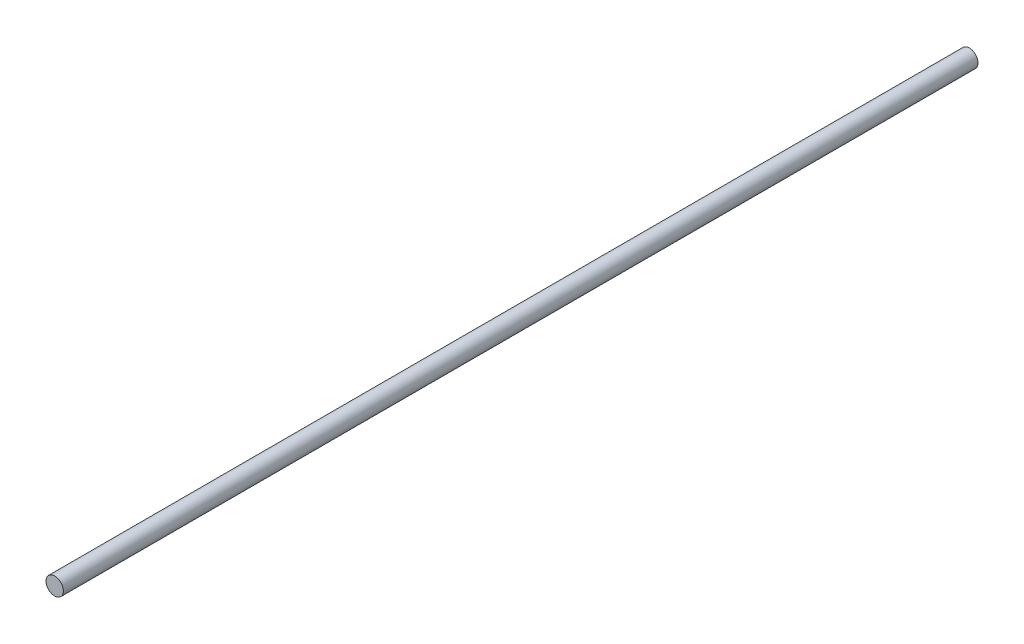
from build123d import *

# Parameters (mm, degrees)
SKETCH2_W = 420.400000948
SKETCH2_H = 4


with BuildPart() as part:
    # Sketch2 → Revolve1 (revolve)
    with BuildSketch(Plane(origin=(0, 0, 0), x_dir=(0, 0, -1), z_dir=(1, 0, 0))):
        with Locations((191.1, 2)):
            Rectangle(SKETCH2_W, SKETCH2_H)
    revolve(axis=Axis((0, 0, 19.100000474), (0, 0, -1)))


solid = part.part
